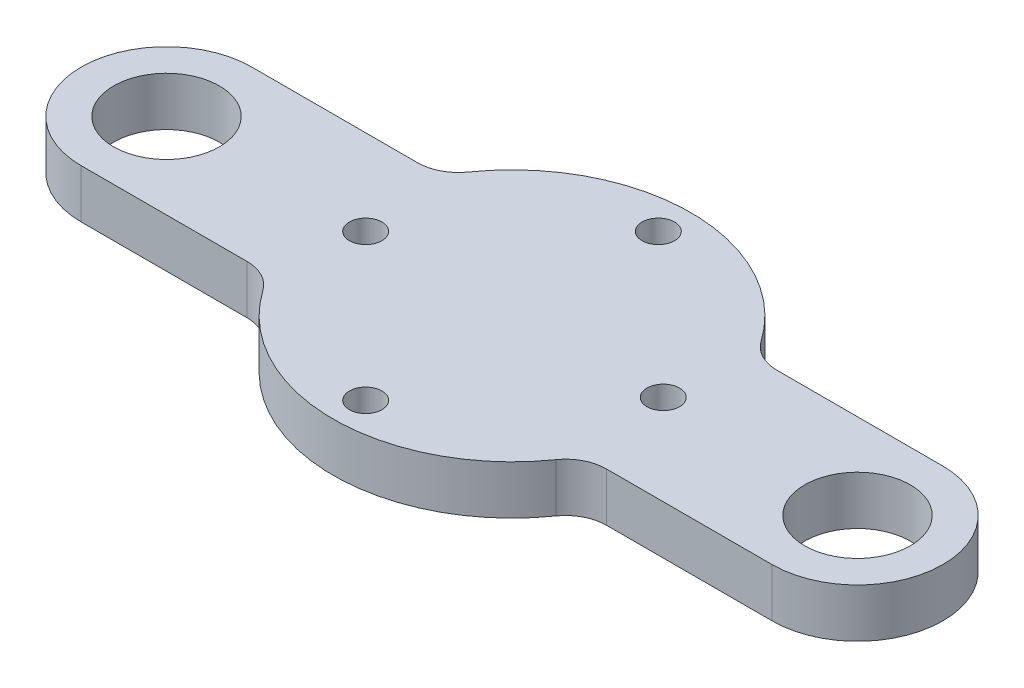
from build123d import *

# Parameters (mm, degrees)
SKETCH1_R           = 2
SKETCH1_R_2         = 6.5
BOSS_EXTRUDE1_DEPTH = 6


with BuildPart() as part:
    # Sketch1 → Boss-Extrude1 (new body)
    with BuildSketch(Plane(origin=(0, 0, 0), x_dir=(1, 0, 0), z_dir=(0, 1, 0))):
        with BuildLine():
            Line((-22.107690969, 10.5), (-42.5, 10.5))
            ThreePointArc((-42.5, 10.5), (-53, 0), (-42.5, -10.5))
            Line((-42.5, -10.5), (-22.107690969, -10.5))
            ThreePointArc((-22.107690969, -10.5), (-19.800295422, -11.06424462), (-18.013674085, -12.629629684))
            ThreePointArc((-18.013674085, -12.629629684), (7.2e-08, -22), (18.013674168, -12.629629566))
            ThreePointArc((18.013674168, -12.629629566), (19.800295486, -11.064244587), (22.107690969, -10.5))
            Line((22.107690969, -10.5), (42.5, -10.5))
            ThreePointArc((42.5, -10.5), (53, 0), (42.5, 10.5))
            Line((42.5, 10.5), (22.107690919, 10.5))
            ThreePointArc((22.107690919, 10.5), (19.800295464, 11.064244598), (18.013674168, 12.629629566))
            ThreePointArc((18.013674168, 12.629629566), (0, 22), (-18.013674168, 12.629629566))
            ThreePointArc((-18.013674168, 12.629629566), (-19.800295486, 11.064244587), (-22.107690969, 10.5))
        make_face()
        with Locations((17.989399487, 0.617661785)):
            Circle(SKETCH1_R, mode=Mode.SUBTRACT)
        with Locations((-42.5, 0)):
            Circle(SKETCH1_R_2, mode=Mode.SUBTRACT)
        with Locations((-18, 0)):
            Circle(SKETCH1_R, mode=Mode.SUBTRACT)
        with Locations((0, -18)):
            Circle(SKETCH1_R, mode=Mode.SUBTRACT)
        with Locations((0, 18)):
            Circle(SKETCH1_R, mode=Mode.SUBTRACT)
        with Locations((42.5, 0)):
            Circle(SKETCH1_R_2, mode=Mode.SUBTRACT)
    extrude(amount=BOSS_EXTRUDE1_DEPTH)


solid = part.part
